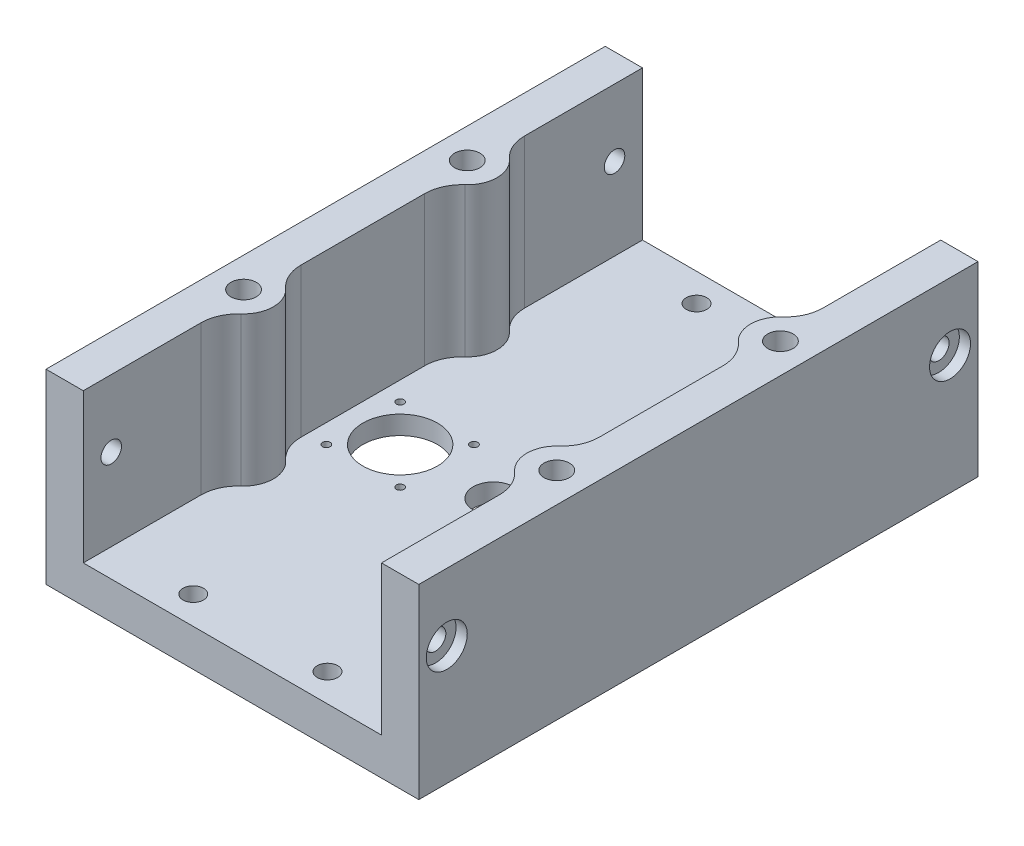
from build123d import *

# Parameters (mm, degrees)
SKETCH1_W                                           = 100
SKETCH1_H                                           = 150
EXTRUDE1_DEPTH                                      = 10
SKETCH2_W                                           = 10
SKETCH2_H                                           = 150
EXTRUDE2_DEPTH                                      = 40
EXTRUDE5_DEPTH                                      = 50
FILLET1_R                                           = 10
LPATTERN1_COUNT                                     = 2
LPATTERN1_PITCH                                     = 60
LPATTERN1_COUNT_DIR2                                = 2
LPATTERN1_PITCH_DIR2                                = 84
SKETCH16_W                                          = 80
SKETCH16_H                                          = 75
EXTRUDE8_DEPTH                                      = 5
FILLET2_R                                           = 6
M2_5_TAPPED_HOLE1_D                                 = 2.05
M2_5_TAPPED_HOLE1_DEPTH                             = 10.00105
EXTRUDE7_START                                      = -10
SKETCH14_R                                          = 10
EXTRUDE7_DEPTH                                      = 5
LPATTERN2_COUNT                                     = 2
LPATTERN2_PITCH                                     = 19.8
LPATTERN2_COUNT_DIR2                                = 2
LPATTERN2_PITCH_DIR2                                = 19.8
MIRROR4_COPY_1_D                                    = 2.05
MIRROR4_COPY_1_DEPTH                                = 10.00105
MIRROR4_COPY_2_D                                    = 2.05
MIRROR4_COPY_2_DEPTH                                = 10.00105
MIRROR4_COPY_3_D                                    = 2.05
MIRROR4_COPY_3_DEPTH                                = 10.00105
F_10_8_10_8_DIAMETER_HOLE1_D                        = 10.8
F_10_8_10_8_DIAMETER_HOLE1_DEPTH                    = 5
CBORE_FOR_M5_HEX_SOCKET_HEAD_CAP_SCREW1_D           = 5.5
CBORE_FOR_M5_HEX_SOCKET_HEAD_CAP_SCREW1_DEPTH       = 10.001
CBORE_FOR_M5_HEX_SOCKET_HEAD_CAP_SCREW1_CBORE_D     = 11
CBORE_FOR_M5_HEX_SOCKET_HEAD_CAP_SCREW1_CBORE_DEPTH = 3
CBORE_FOR_M5_HEX_SOCKET_HEAD_CAP_SCREW2_D           = 5.5
CBORE_FOR_M5_HEX_SOCKET_HEAD_CAP_SCREW2_DEPTH       = 10.00105
CBORE_FOR_M5_HEX_SOCKET_HEAD_CAP_SCREW2_CBORE_D     = 10
CBORE_FOR_M5_HEX_SOCKET_HEAD_CAP_SCREW2_CBORE_DEPTH = 5
MIRROR6_COPY_1_D                                    = 5.5
MIRROR6_COPY_1_DEPTH                                = 10.001
MIRROR6_COPY_1_CBORE_D                              = 11
MIRROR6_COPY_1_CBORE_DEPTH                          = 3


with BuildPart() as part:
    # Sketch1 → Extrude1 (new body)
    with BuildSketch(Plane(origin=(0, 0, 0), x_dir=(1, 0, 0), z_dir=(0, 1, 0))):
        with Locations((0, 75)):
            Rectangle(SKETCH1_W, SKETCH1_H)
    extrude(amount=-EXTRUDE1_DEPTH)

    # Sketch2 → Extrude2 (add)
    with BuildSketch(Plane(origin=(0, 0, 0), x_dir=(1, 0, 0), z_dir=(0, 1, 0))):
        with Locations((-45, 75)):
            Rectangle(SKETCH2_W, SKETCH2_H)
        with Locations((45, 75)):
            Rectangle(SKETCH2_W, SKETCH2_H)
    extrude(amount=EXTRUDE2_DEPTH)

    # Sketch6 → Extrude5 (add)
    with BuildSketch(Plane(origin=(0, 40, 0), x_dir=(1, 0, 0), z_dir=(0, 1, 0))):
        with BuildLine():
            Line((42, 53), (50, 53))
            Line((50, 53), (50, 37))
            Line((50, 37), (42, 37))
            ThreePointArc((42, 37), (34, 45), (42, 53))
        make_face()
        with BuildLine():
            Line((42, 113), (50, 113))
            Line((50, 113), (50, 97))
            Line((50, 97), (42, 97))
            ThreePointArc((42, 97), (34, 105), (42, 113))
        make_face()
    extrude5 = extrude(amount=-EXTRUDE5_DEPTH)

    # Mirror2: Extrude5 across plane
    add(extrude5.mirror(Plane(origin=(0, 0, 0), x_dir=(0, 0, 1), z_dir=(1, 0, 0))))

    # Fillet1
    fillet1_edges = [part.edges().sort_by_distance(p)[0] for p in [
        (40, 20, -112.745966692),
        (40, 20, -97.254033308),
        (40, 20, -52.745966692),
        (40, 20, -37.254033308),
        (-40, 20, -97.254033308),
        (-40, 20, -112.745966692),
        (-40, 20, -37.254033308),
        (-40, 20, -52.745966692),
    ]]
    fillet(fillet1_edges, radius=FILLET1_R)

    # Sketch12 → M8 Tapped Hole1 (revolve, cut)
    with BuildSketch(Plane(origin=(42, 40, -45), x_dir=(0, 0, 1), z_dir=(1, 0, 0))):
        Polygon((0, 0), (0, 24.042926105), (3.4, 22), (3.4, 0), align=None)
    m8_tapped_hole1 = revolve(axis=Axis((42, 46.35, -45), (0, -1, 0)), mode=Mode.SUBTRACT)

    # LPattern1: M8 Tapped Hole1 2 × 2
    with Locations(*[(-j * LPATTERN1_PITCH_DIR2, 0, -i * LPATTERN1_PITCH) for i in range(LPATTERN1_COUNT) for j in range(LPATTERN1_COUNT_DIR2) if (i, j) != (0, 0)]):
        add(m8_tapped_hole1, mode=Mode.SUBTRACT)

    # Sketch16 → Extrude8 (cut)
    with BuildSketch(Plane.XZ.offset(10)):
        with Locations((0, -52.5)):
            Rectangle(SKETCH16_W, SKETCH16_H)
    extrude(amount=-EXTRUDE8_DEPTH, mode=Mode.SUBTRACT)

    # Fillet2
    fillet2_edges = [part.edges().sort_by_distance(p)[0] for p in [
        (-40, -7.5, -90),
        (-40, -7.5, -15),
        (40, -7.5, -15),
        (40, -7.5, -90),
    ]]
    fillet(fillet2_edges, radius=FILLET2_R)

    # M2.5 Tapped Hole1
    with Locations(Plane(origin=(-34.9, -10, -60.1), x_dir=(0, 0, -1), z_dir=(0, -1, 0))):
        with Locations((0, 0)):
            m2_5_tapped_hole1 = Hole(M2_5_TAPPED_HOLE1_D / 2, depth=M2_5_TAPPED_HOLE1_DEPTH)

    # Sketch14 → Extrude7 (cut)
    with BuildSketch(Plane.XZ.offset(10).offset(EXTRUDE7_START)):
        with Locations(Location((-25, -70, 0), (0, 0, 270))):  # turned: the seam where the file's is
            Circle(SKETCH14_R)
    extrude7 = extrude(amount=EXTRUDE7_DEPTH, mode=Mode.SUBTRACT)

    # LPattern2: M2.5 Tapped Hole1 2 × 2
    with Locations(*[(i * LPATTERN2_PITCH, 0, -j * LPATTERN2_PITCH_DIR2) for i in range(LPATTERN2_COUNT) for j in range(LPATTERN2_COUNT_DIR2) if (i, j) != (0, 0)]):
        add(m2_5_tapped_hole1, mode=Mode.SUBTRACT)

    # Mirror4: Extrude7, M2.5 Tapped Hole1 across plane
    add(extrude7.mirror(Plane(origin=(0, 0, 0), x_dir=(0, 0, 1), z_dir=(1, 0, 0))), mode=Mode.SUBTRACT)
    add(m2_5_tapped_hole1.mirror(Plane(origin=(0, 0, 0), x_dir=(0, 0, 1), z_dir=(1, 0, 0))), mode=Mode.SUBTRACT)

    # Mirror4 copy 1
    with Locations(Plane(origin=(34.9, -10, -79.9), x_dir=(0, 0, -1), z_dir=(0, -1, 0))):
        with Locations((0, 0)):
            Hole(MIRROR4_COPY_1_D / 2, depth=MIRROR4_COPY_1_DEPTH)

    # Mirror4 copy 2
    with Locations(Plane(origin=(15.1, -10, -60.1), x_dir=(0, 0, -1), z_dir=(0, -1, 0))):
        with Locations((0, 0)):
            Hole(MIRROR4_COPY_2_D / 2, depth=MIRROR4_COPY_2_DEPTH)

    # Mirror4 copy 3
    with Locations(Plane(origin=(15.1, -10, -79.9), x_dir=(0, 0, -1), z_dir=(0, -1, 0))):
        with Locations((0, 0)):
            Hole(MIRROR4_COPY_3_D / 2, depth=MIRROR4_COPY_3_DEPTH)

    # Ø10.8 (10.8) Diameter Hole1
    with Locations(Plane.XZ.offset(5)):
        with Locations((0, -70)):
            Hole(F_10_8_10_8_DIAMETER_HOLE1_D / 2, depth=F_10_8_10_8_DIAMETER_HOLE1_DEPTH)

    # CBORE for M5 Hex Socket Head Cap Screw1
    with Locations(Plane.ZY.offset(50)):
        with Locations((-7.5, 22)):
            cbore_for_m5_hex_socket_head_cap_screw1 = CounterBoreHole(CBORE_FOR_M5_HEX_SOCKET_HEAD_CAP_SCREW1_D / 2, CBORE_FOR_M5_HEX_SOCKET_HEAD_CAP_SCREW1_CBORE_D / 2, CBORE_FOR_M5_HEX_SOCKET_HEAD_CAP_SCREW1_CBORE_DEPTH, depth=CBORE_FOR_M5_HEX_SOCKET_HEAD_CAP_SCREW1_DEPTH)

    # Mirror5: CBORE for M5 Hex Socket Head Cap Screw1 across plane
    add(cbore_for_m5_hex_socket_head_cap_screw1.mirror(Plane(origin=(0, 0, 0), x_dir=(0, 0, 1), z_dir=(1, 0, 0))), mode=Mode.SUBTRACT)

    # CBORE for M5 Hex Socket Head Cap Screw2
    with Locations(Plane.XZ.offset(10)):
        with Locations((-18, -7.5), (18, -7.5)):
            cbore_for_m5_hex_socket_head_cap_screw2 = CounterBoreHole(CBORE_FOR_M5_HEX_SOCKET_HEAD_CAP_SCREW2_D / 2, CBORE_FOR_M5_HEX_SOCKET_HEAD_CAP_SCREW2_CBORE_D / 2, CBORE_FOR_M5_HEX_SOCKET_HEAD_CAP_SCREW2_CBORE_DEPTH, depth=CBORE_FOR_M5_HEX_SOCKET_HEAD_CAP_SCREW2_DEPTH)

    # Mirror6: CBORE for M5 Hex Socket Head Cap Screw2, CBORE for M5 Hex Socket Head Cap Screw1 across plane
    add(cbore_for_m5_hex_socket_head_cap_screw2.mirror(Plane.XY.offset(-75)), mode=Mode.SUBTRACT)
    add(cbore_for_m5_hex_socket_head_cap_screw1.mirror(Plane.XY.offset(-75)), mode=Mode.SUBTRACT)

    # Mirror6 copy 1
    with Locations(Plane(origin=(50, 0, -150), x_dir=(0, 0, -1), z_dir=(1, 0, 0))):
        with Locations((-7.5, 22)):
            CounterBoreHole(MIRROR6_COPY_1_D / 2, MIRROR6_COPY_1_CBORE_D / 2, MIRROR6_COPY_1_CBORE_DEPTH, depth=MIRROR6_COPY_1_DEPTH)


solid = part.part
